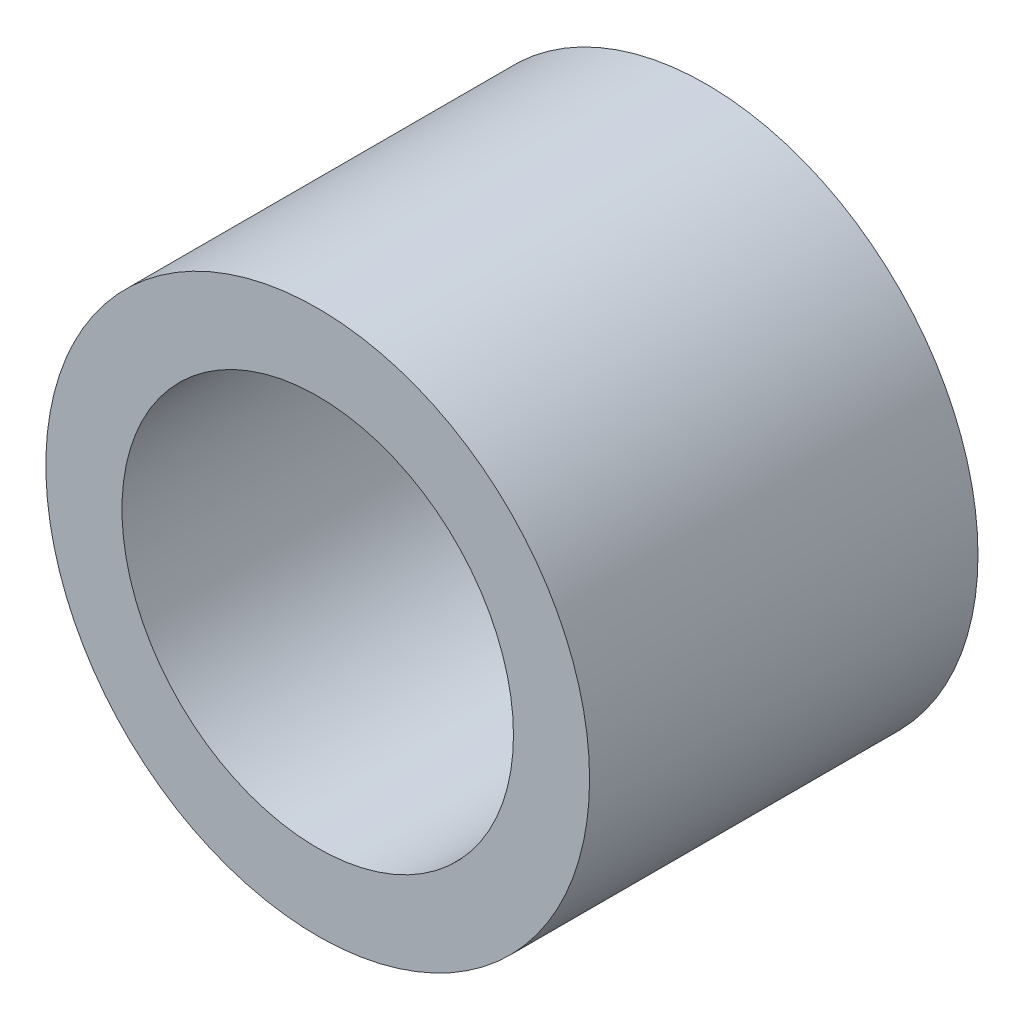
from build123d import *

# Parameters (mm, degrees)
SKETCH1_R      = 11.1125
SKETCH1_R_2    = 8.001
EXTRUDE1_DEPTH = 7.9375


with BuildPart() as part:
    # Sketch1 → Extrude1 (new body, symmetric)
    with BuildSketch(Plane.XY):
        Circle(SKETCH1_R)
        Circle(SKETCH1_R_2, mode=Mode.SUBTRACT)
    extrude(amount=EXTRUDE1_DEPTH, both=True)


solid = part.part
